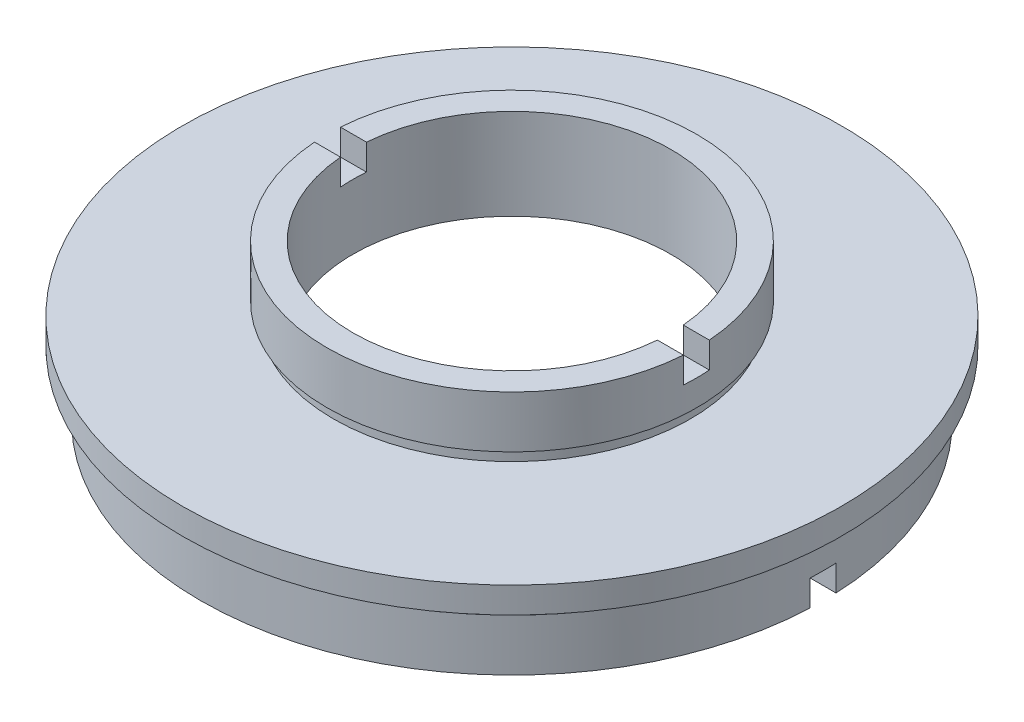
from build123d import *

# Parameters (mm, degrees)
SKETCH_2_W          = 2
SKETCH_2_H          = 3.593987872
SKETCH_2_H_2        = 6.667892238
CUT_EXTRUDE_1_DEPTH = 39.5


with BuildPart() as part:
    # 草图1 → 旋转1 (revolve)
    with BuildSketch(Plane.XY, mode=Mode.PRIVATE) as revolve_1_sk:
        Polygon((-12.25, 12), (-14.25, 12), (-14.25, 8), (-13.75, 8), (-13.75, 7), (-25.4, 7), (-25.4, 5), (-23.5, 5), (-23.5, 4), (-24, 4), (-24, 0), (-20.5, 0), (-20.5, 4), (-21.1, 4), (-21.1, 5), (-12.25, 5), align=None)
    revolve(revolve_1_sk.sketch.rotate(Axis((0, 22.677499451, 0), (0, -1, 0)), 270), axis=Axis((0, 22.677499451, 0), (0, -1, 0)))  # turned: the seam where the file's is

    # 草图2 → 切除-拉伸1 (cut, symmetric)
    with BuildSketch(Plane(origin=(0, 0, 0), x_dir=(0, 0, -1), z_dir=(1, 0, 0))):
        with Locations((0, 11.796993936)):
            Rectangle(SKETCH_2_W, SKETCH_2_H)
        with Locations((0, -1.333946119)):
            Rectangle(SKETCH_2_W, SKETCH_2_H_2)
    extrude(amount=CUT_EXTRUDE_1_DEPTH, both=True, mode=Mode.SUBTRACT)


solid = part.part
